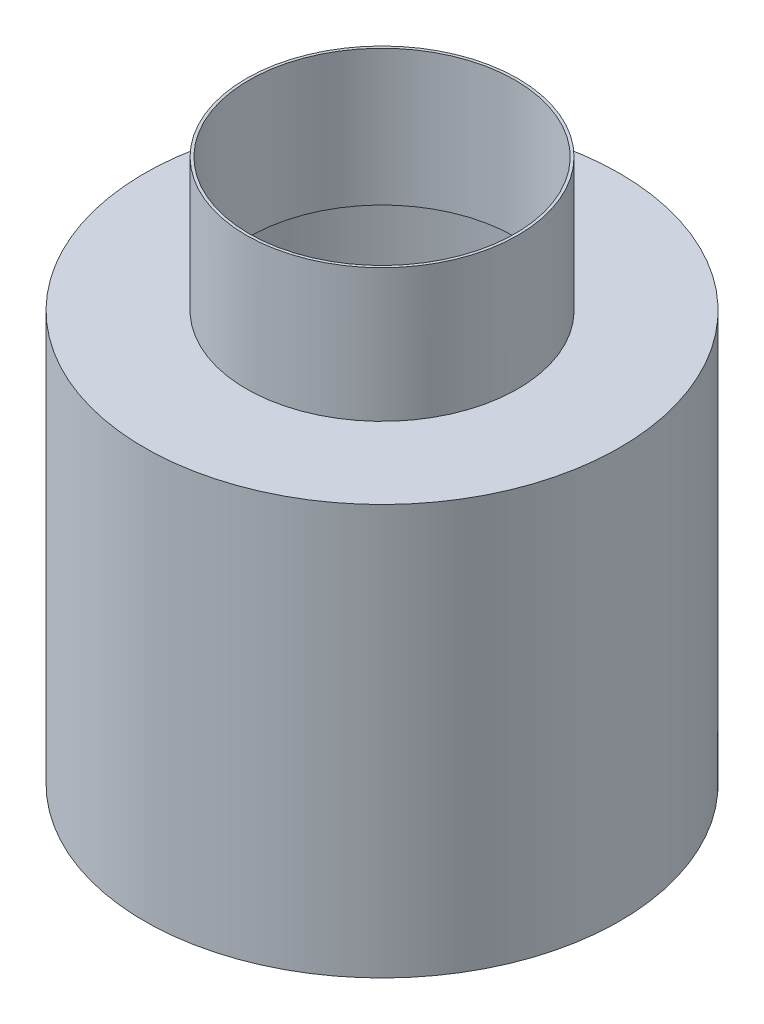
from build123d import *

# Parameters (mm, degrees)
SKETCH1_R           = 100
BOSS_EXTRUDE1_DEPTH = 98
SKETCH3_R           = 98
CUT_EXTRUDE2_DEPTH  = 397
SKETCH5_R           = 175
SKETCH5_R_2         = 98
BOSS_EXTRUDE2_DEPTH = 2
SKETCH7_R           = 175
SKETCH7_R_2         = 173
BOSS_EXTRUDE3_DEPTH = 300
SKETCH8_R           = 175
BOSS_EXTRUDE4_DEPTH = 2


with BuildPart() as part:
    # Sketch1 → Boss-Extrude1 (new body)
    with BuildSketch(Plane(origin=(0, 0, 0), x_dir=(1, 0, 0), z_dir=(0, 1, 0))):
        Circle(SKETCH1_R)
    extrude(amount=BOSS_EXTRUDE1_DEPTH)

    # Sketch3 → Cut-Extrude2 (cut)
    with BuildSketch(Plane(origin=(0, 98, 0), x_dir=(1, 0, 0), z_dir=(0, 1, 0))):
        Circle(SKETCH3_R)
    extrude(amount=-CUT_EXTRUDE2_DEPTH, mode=Mode.SUBTRACT)

    # Sketch5 → Boss-Extrude2 (add)
    with BuildSketch(Plane.XZ):
        Circle(SKETCH5_R)
        Circle(SKETCH5_R_2, mode=Mode.SUBTRACT)
    extrude(amount=BOSS_EXTRUDE2_DEPTH)

    # Sketch7 → Boss-Extrude3 (add)
    with BuildSketch(Plane.XZ.offset(2)):
        Circle(SKETCH7_R)
        Circle(SKETCH7_R_2, mode=Mode.SUBTRACT)
    extrude(amount=BOSS_EXTRUDE3_DEPTH)

    # Sketch8 → Boss-Extrude4 (add)
    with BuildSketch(Plane.XZ.offset(302)):
        Circle(SKETCH8_R)
    extrude(amount=-BOSS_EXTRUDE4_DEPTH)


solid = part.part
